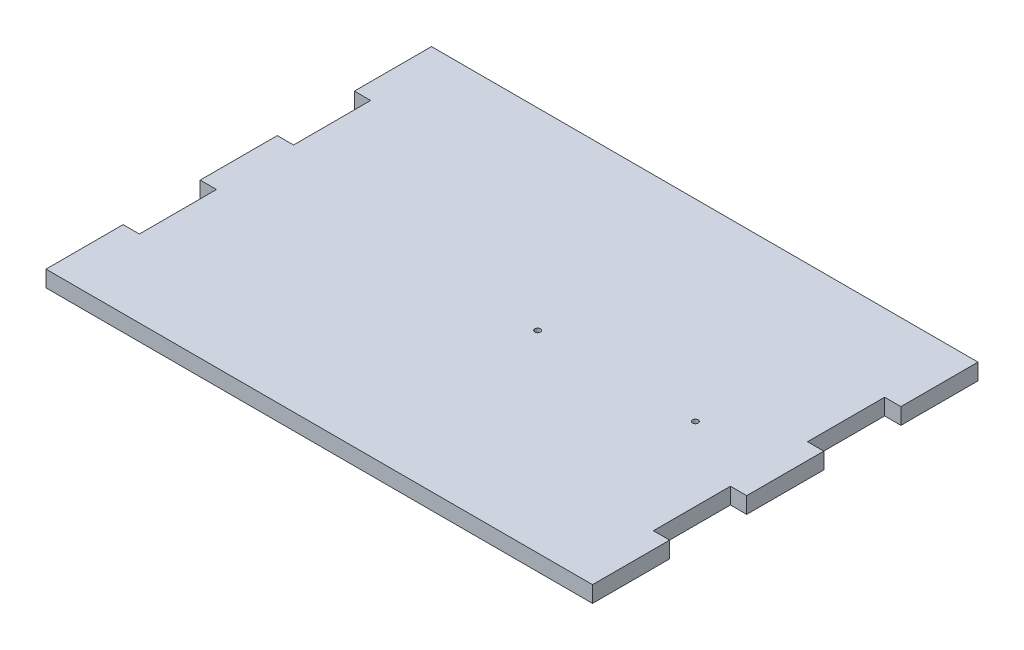
from build123d import *

# Parameters (mm, degrees)
SKETCH3_W           = 192
SKETCH3_H           = 135
BOSS_EXTRUDE1_DEPTH = 5.7
CUT_EXTRUDE1_DEPTH  = 6
SKETCH11_R          = 1
CUT_EXTRUDE2_DEPTH  = 33


with BuildPart() as part:
    # Sketch3 → Boss-Extrude1 (new body)
    with BuildSketch(Plane(origin=(0, 0, 0), x_dir=(1, 0, 0), z_dir=(0, 1, 0))):
        with Locations((90, 53.5)):
            Rectangle(SKETCH3_W, SKETCH3_H)
    extrude(amount=BOSS_EXTRUDE1_DEPTH)

    # Sketch4 → Cut-Extrude1 (cut)
    with BuildSketch(Plane(origin=(0, 0, 0), x_dir=(1, 0, 0), z_dir=(0, 1, 0))):
        Polygon((-5.7, 121.001666615), (-5.7, 94), (0, 94), (0, 67), (-5.7, 67), (-5.7, 40), (0, 40), (0, 13), (-5.7, 13), (-5.7, -17), (-9.7, -17), (-9.7, 121.001666615), align=None)
        Polygon((189.7, 121.001666615), (185.7, 121.001666615), (185.7, 94), (180, 94), (180, 67), (185.7, 67), (185.7, 40), (180, 40), (180, 13), (185.7, 13), (185.7, -17), (189.7, -17), align=None)
    extrude(amount=CUT_EXTRUDE1_DEPTH, mode=Mode.SUBTRACT)

    # Sketch11 → Cut-Extrude2 (cut)
    with BuildSketch(Plane(origin=(0, 0, 0), x_dir=(1, 0, 0), z_dir=(0, 1, 0))):
        with Locations((99, 53.5)):
            Circle(SKETCH11_R)
        with Locations((154.2, 53.5)):
            Circle(SKETCH11_R)
    extrude(amount=CUT_EXTRUDE2_DEPTH, mode=Mode.SUBTRACT)


solid = part.part
